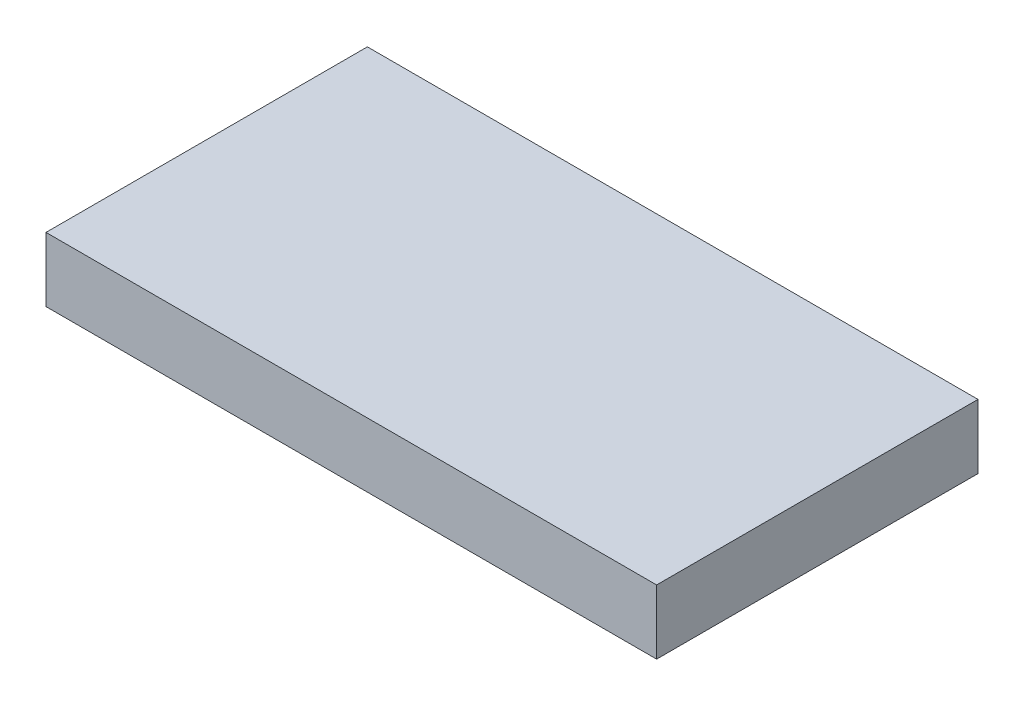
from build123d import *

# Parameters (mm, degrees)
SKETCH1_W           = 1.9
SKETCH1_H           = 1
BOSS_EXTRUDE1_DEPTH = 0.2


with BuildPart() as part:
    # Sketch1 → Boss-Extrude1 (new body)
    with BuildSketch(Plane(origin=(0, 0, 0), x_dir=(1, 0, 0), z_dir=(0, 1, 0))):
        with Locations((0.05, 0)):
            Rectangle(SKETCH1_W, SKETCH1_H)
    extrude(amount=BOSS_EXTRUDE1_DEPTH)


solid = part.part
